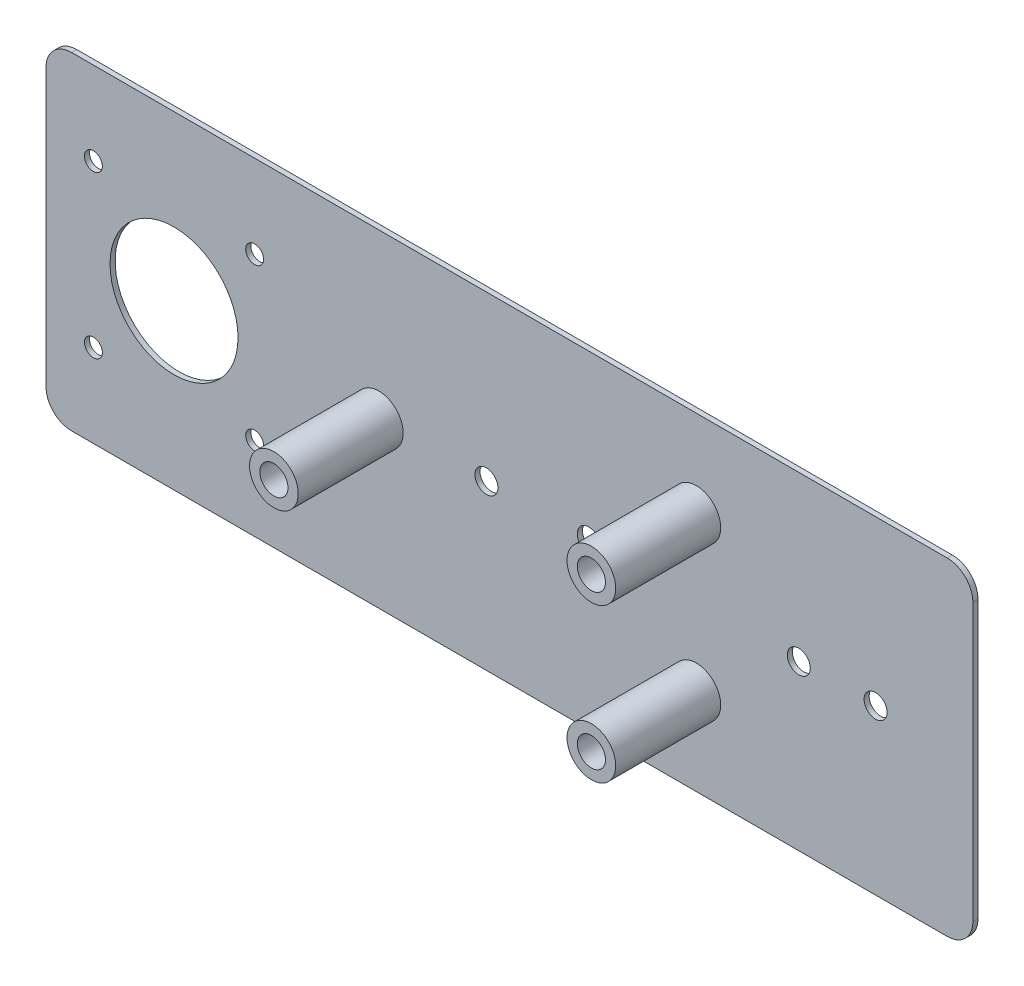
from build123d import *

# Parameters (mm, degrees)
BOSS_EXTRUDE1_DEPTH = 37
SKETCH2_R           = 1.75
SKETCH2_R_2         = 12.5
SKETCH2_R_3         = 2.75
SKETCH2_R_4         = 2.25
CUT_EXTRUDE1_DEPTH  = 38
SKETCH5_R           = 2.25
CUT_EXTRUDE2_DEPTH  = 38
CUT_EXTRUDE3_DEPTH  = 36
SKETCH7_R           = 4.75
BOSS_EXTRUDE2_DEPTH = 20.5
SKETCH10_W          = 40
SKETCH10_H          = 64
CUT_EXTRUDE4_DEPTH  = 36
SKETCH11_R          = 2.75
CUT_EXTRUDE5_DEPTH  = 22.5
SKETCH12_W          = 15
SKETCH12_H          = 10
SKETCH12_W_2        = 20
SKETCH12_W_3        = 10
BOSS_EXTRUDE3_DEPTH = 36
CUT_EXTRUDE6_DEPTH  = 33
CUT_EXTRUDE8_DEPTH  = 15
CUT_EXTRUDE9_DEPTH  = 15
CUT_EXTRUDE10_DEPTH = 10
CUT_EXTRUDE11_DEPTH = 10
SKETCH20_W          = 6
SKETCH20_H          = 15
CUT_EXTRUDE12_DEPTH = 3
SKETCH21_W          = 76
SKETCH21_H          = 64
SKETCH21_W_2        = 9.5
SKETCH21_H_2        = 9.5
SKETCH21_W_3        = 65
CUT_EXTRUDE13_DEPTH = 36


with BuildPart() as part:
    # Sketch1 → Boss-Extrude1 (new body)
    with BuildSketch(Plane.XY):
        with BuildLine():
            Line((-85.5, 32), (85.5, 32))
            ThreePointArc((85.5, 32), (89.035533906, 30.535533906), (90.5, 27))
            Line((90.5, 27), (90.5, -27))
            ThreePointArc((90.5, -27), (89.035533906, -30.535533906), (85.5, -32))
            Line((85.5, -32), (-85.5, -32))
            ThreePointArc((-85.5, -32), (-89.035533906, -30.535533906), (-90.5, -27))
            Line((-90.5, -27), (-90.5, 27))
            ThreePointArc((-90.5, 27), (-89.035533906, 30.535533906), (-85.5, 32))
        make_face()
    extrude(amount=BOSS_EXTRUDE1_DEPTH)

    # Sketch2 → Cut-Extrude1 (cut, through all)
    with BuildSketch(Plane.XY.offset(37)):
        with Locations((-81.25, 15.75)):
            Circle(SKETCH2_R)
        with Locations((-49.75, 15.75)):
            Circle(SKETCH2_R)
        with Locations((-81.25, -15.75)):
            Circle(SKETCH2_R)
        with Locations((-49.75, -15.75)):
            Circle(SKETCH2_R)
        with Locations((-65.5, 0)):
            Circle(SKETCH2_R_2)
        with Locations((36.5, 15)):
            Circle(SKETCH2_R_3)
        with Locations((36.5, -15)):
            Circle(SKETCH2_R_3)
        with Locations((-25.5, 0)):
            Circle(SKETCH2_R_3)
        with Locations((56.5, 0)):
            Circle(SKETCH2_R_4)
        with Locations((71.5, 0)):
            Circle(SKETCH2_R_4)
    extrude(amount=-CUT_EXTRUDE1_DEPTH, mode=Mode.SUBTRACT)

    # Sketch5 → Cut-Extrude2 (cut, through all)
    with BuildSketch(Plane.XY.offset(37)):
        with Locations((-4.5, 0)):
            Circle(SKETCH5_R)
        with Locations((15.5, 0)):
            Circle(SKETCH5_R)
    extrude(amount=-CUT_EXTRUDE2_DEPTH, mode=Mode.SUBTRACT)

    # Sketch6 → Cut-Extrude3 (cut)
    with BuildSketch(Plane.XY.offset(37)):
        with BuildLine():
            Line((-85.5, -29), (85.5, -29))
            ThreePointArc((85.5, -29), (86.914213562, -28.414213562), (87.5, -27))
            Line((87.5, -27), (87.5, 27))
            ThreePointArc((87.5, 27), (86.914213562, 28.414213562), (85.5, 29))
            Line((85.5, 29), (-85.5, 29))
            ThreePointArc((-85.5, 29), (-86.914213562, 28.414213562), (-87.5, 27))
            Line((-87.5, 27), (-87.5, -27))
            ThreePointArc((-87.5, -27), (-86.914213562, -28.414213562), (-85.5, -29))
        make_face()
    extrude(amount=-CUT_EXTRUDE3_DEPTH, mode=Mode.SUBTRACT)

    # Sketch7 → Boss-Extrude2 (add)
    with BuildSketch(Plane.XY.offset(1)):
        with Locations((-25.5, 0)):
            Circle(SKETCH7_R)
        with Locations((36.5, -15)):
            Circle(SKETCH7_R)
        with Locations((36.5, 15)):
            Circle(SKETCH7_R)
    extrude(amount=BOSS_EXTRUDE2_DEPTH)

    # Sketch10 → Cut-Extrude4 (cut)
    with BuildSketch(Plane.XY.offset(37)):
        with Locations((5.5, 0)):
            Rectangle(SKETCH10_W, SKETCH10_H)
    extrude(amount=-CUT_EXTRUDE4_DEPTH, mode=Mode.SUBTRACT)

    # Sketch11 → Cut-Extrude5 (cut, through all)
    with BuildSketch(Plane.XY.offset(21.5)):
        with Locations((36.5, -15)):
            Circle(SKETCH11_R)
        with Locations((-25.5, 0)):
            Circle(SKETCH11_R)
        with Locations((36.5, 15)):
            Circle(SKETCH11_R)
    extrude(amount=-CUT_EXTRUDE5_DEPTH, mode=Mode.SUBTRACT)

    # Sketch12 → Boss-Extrude3 (add, through all)
    with BuildSketch(Plane.XY.offset(1)):
        with Locations((75, -24)):
            Rectangle(SKETCH12_W, SKETCH12_H)
        with Locations((75, 24)):
            Rectangle(SKETCH12_W, SKETCH12_H)
        with Locations((77.5, -11)):
            Rectangle(SKETCH12_W_2, SKETCH12_H)
        with Locations((77.5, 11)):
            Rectangle(SKETCH12_W_2, SKETCH12_H)
        with Locations((-37.5, -24)):
            Rectangle(SKETCH12_W_3, SKETCH12_H)
        with Locations((-37.5, 24)):
            Rectangle(SKETCH12_W_3, SKETCH12_H)
    extrude(amount=BOSS_EXTRUDE3_DEPTH)

    # Sketch14 → Cut-Extrude6 (cut)
    with BuildSketch(Plane.XZ.offset(16)):
        Polygon((87.5, 37), (67.5, 37), (67.5, 3), align=None)
    extrude(amount=-CUT_EXTRUDE6_DEPTH, mode=Mode.SUBTRACT)

    # Sketch16 → Cut-Extrude8 (cut)
    with BuildSketch(Plane(origin=(82.5, 0, 0), x_dir=(0, 0, -1), z_dir=(1, 0, 0))):
        Polygon((-37, -19), (-3, -19), (-37, -29), align=None)
    extrude(amount=-CUT_EXTRUDE8_DEPTH, mode=Mode.SUBTRACT)

    # Sketch17 → Cut-Extrude9 (cut)
    with BuildSketch(Plane.ZY.offset(-67.5)):
        Polygon((37, 19), (1, 19), (37, 29), align=None)
    extrude(amount=-CUT_EXTRUDE9_DEPTH, mode=Mode.SUBTRACT)

    # Sketch18 → Cut-Extrude10 (cut)
    with BuildSketch(Plane(origin=(-32.5, 0, 0), x_dir=(0, 0, -1), z_dir=(1, 0, 0))):
        Polygon((-37, -29), (-37, -19), (-1, -19), align=None)
    extrude(amount=-CUT_EXTRUDE10_DEPTH, mode=Mode.SUBTRACT)

    # Sketch19 → Cut-Extrude11 (cut)
    with BuildSketch(Plane(origin=(-32.5, 0, 0), x_dir=(0, 0, -1), z_dir=(1, 0, 0))):
        Polygon((-37, 29), (-1, 19), (-37, 19), align=None)
    extrude(amount=-CUT_EXTRUDE11_DEPTH, mode=Mode.SUBTRACT)

    # Sketch20 → Cut-Extrude12 (cut)
    with BuildSketch(Plane.ZY.offset(90.5)):
        with Locations((30, 0)):
            Rectangle(SKETCH20_W, SKETCH20_H)
    extrude(amount=-CUT_EXTRUDE12_DEPTH, mode=Mode.SUBTRACT)

    # Sketch21 → Cut-Extrude13 (cut)
    with BuildSketch(Plane.XY.offset(37)):
        with Locations((-52.5, 0)):
            Rectangle(SKETCH21_W, SKETCH21_H)
        with Locations((-25.5, 0)):
            Rectangle(SKETCH21_W_2, SKETCH21_H_2, mode=Mode.SUBTRACT)
        with Locations((58, 0)):
            Rectangle(SKETCH21_W_3, SKETCH21_H)
        with Locations((36.5, -15)):
            Rectangle(SKETCH21_W_2, SKETCH21_H_2, mode=Mode.SUBTRACT)
        with Locations((36.5, 15)):
            Rectangle(SKETCH21_W_2, SKETCH21_H_2, mode=Mode.SUBTRACT)
    extrude(amount=-CUT_EXTRUDE13_DEPTH, mode=Mode.SUBTRACT)


solid = part.part
